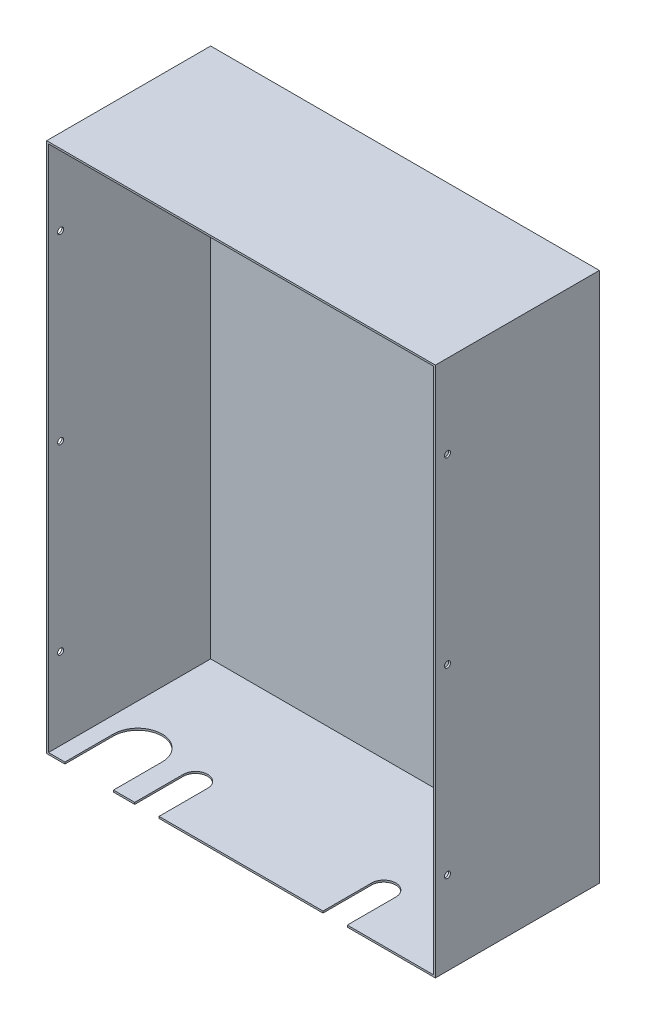
from build123d import *

# Parameters (mm, degrees)
CROQUIS1_W              = 320
CROQUIS1_H              = 437
SALIENTE_EXTRUIR1_DEPTH = 1.5
CROQUIS2_W              = 317
CROQUIS2_H              = 434
SALIENTE_EXTRUIR2_DEPTH = 135
CORTAR_EXTRUIR1_DEPTH   = 1.5
CORTAR_EXTRUIR2_DEPTH   = 1.5
CROQUIS6_R              = 2.5
CORTAR_EXTRUIR4_DEPTH   = 320


with BuildPart() as part:
    # Croquis1 → Saliente-Extruir1 (new body)
    with BuildSketch(Plane.XY):
        with Locations((-160, 218.5)):
            Rectangle(CROQUIS1_W, CROQUIS1_H)
    extrude(amount=SALIENTE_EXTRUIR1_DEPTH)

    # Croquis2 → Saliente-Extruir2 (add)
    with BuildSketch(Plane.XY):
        Polygon((0, 436), (0, 437), (-1, 437), (-319, 437), (-320, 437), (-320, 436), (-320, 1), (-320, 0), (-319, 0), (-1, 0), (0, 0), (0, 1), align=None)
        with Locations((-160, 218.5)):
            Rectangle(CROQUIS2_W, CROQUIS2_H, mode=Mode.SUBTRACT)
    extrude(amount=SALIENTE_EXTRUIR2_DEPTH)

    # Croquis3 → Cortar-Extruir1 (cut)
    with BuildSketch(Plane.XZ):
        with BuildLine():
            Line((-247.5, 95), (-247.5, 135))
            Line((-247.5, 135), (-227.5, 135))
            Line((-227.5, 135), (-227.5, 95))
            ThreePointArc((-227.5, 95), (-237.5, 85), (-247.5, 95))
        make_face()
        with BuildLine():
            Line((-92.5, 95), (-92.5, 135))
            Line((-92.5, 135), (-72.5, 135))
            Line((-72.5, 135), (-72.5, 95))
            ThreePointArc((-72.5, 95), (-82.5, 85), (-92.5, 95))
        make_face()
    extrude(amount=-CORTAR_EXTRUIR1_DEPTH, mode=Mode.SUBTRACT)

    # Croquis4 → Cortar-Extruir2 (cut)
    with BuildSketch(Plane.XZ):
        with BuildLine():
            Line((-305, 95), (-305, 135))
            Line((-305, 135), (-265, 135))
            Line((-265, 135), (-265, 95))
            ThreePointArc((-265, 95), (-285, 75), (-305, 95))
        make_face()
    extrude(amount=-CORTAR_EXTRUIR2_DEPTH, mode=Mode.SUBTRACT)

    # Croquis6 → Cortar-Extruir4 (cut)
    with BuildSketch(Plane.ZY.offset(320)):
        with Locations((125, 368.5)):
            Circle(CROQUIS6_R)
        with Locations((125, 68.5)):
            Circle(CROQUIS6_R)
        with Locations((125, 218.5)):
            Circle(CROQUIS6_R)
    extrude(amount=-CORTAR_EXTRUIR4_DEPTH, mode=Mode.SUBTRACT)


solid = part.part
